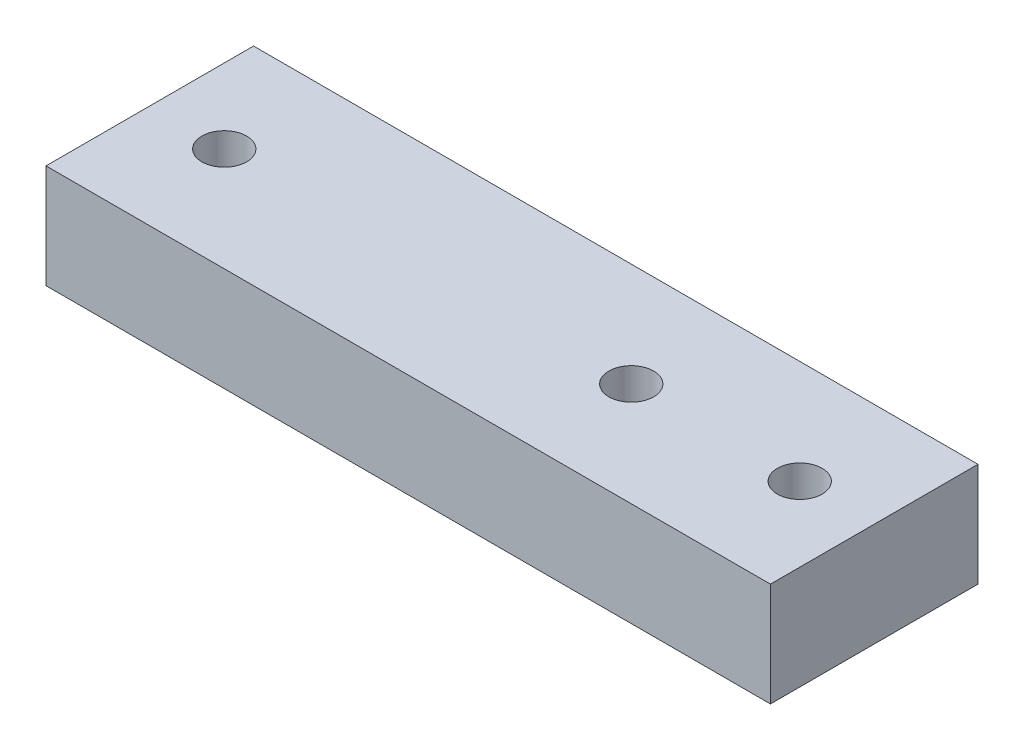
from build123d import *

# Parameters (mm, degrees)
ESBO_O1_W                = 89
ESBO_O1_H                = 25.5
ESBO_O1_R                = 2.75
RESSALTO_EXTRUS_O1_DEPTH = 12.75


with BuildPart() as part:
    # Esboço1 → Ressalto-extrusão1 (new body)
    with BuildSketch(Plane(origin=(0, 0, 0), x_dir=(1, 0, 0), z_dir=(0, 1, 0))):
        with Locations((-44.5, 12.75)):
            Rectangle(ESBO_O1_W, ESBO_O1_H)
        with Locations((-79.85, 12.75)):
            Circle(ESBO_O1_R, mode=Mode.SUBTRACT)
        with Locations((-9.15, 12.75)):
            Circle(ESBO_O1_R, mode=Mode.SUBTRACT)
        with Locations((-29.85, 12.75)):
            Circle(ESBO_O1_R, mode=Mode.SUBTRACT)
    extrude(amount=RESSALTO_EXTRUS_O1_DEPTH)


solid = part.part
